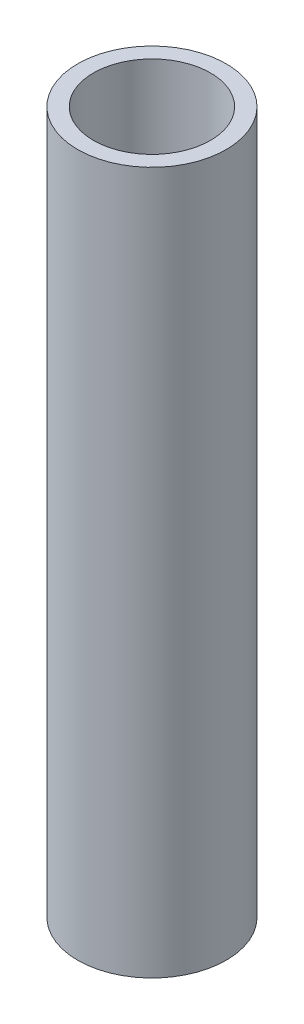
from build123d import *

# Parameters (mm, degrees)
ESQUISSE1_R        = 3.175
ESQUISSE1_R_2      = 2.5
BOSS_EXTRU_1_DEPTH = 30


with BuildPart() as part:
    # Esquisse1 → Boss.-Extru.1 (new body)
    with BuildSketch(Plane(origin=(0, 0, 0), x_dir=(1, 0, 0), z_dir=(0, 1, 0))):
        Circle(ESQUISSE1_R)
        Circle(ESQUISSE1_R_2, mode=Mode.SUBTRACT)
    extrude(amount=BOSS_EXTRU_1_DEPTH)


solid = part.part
